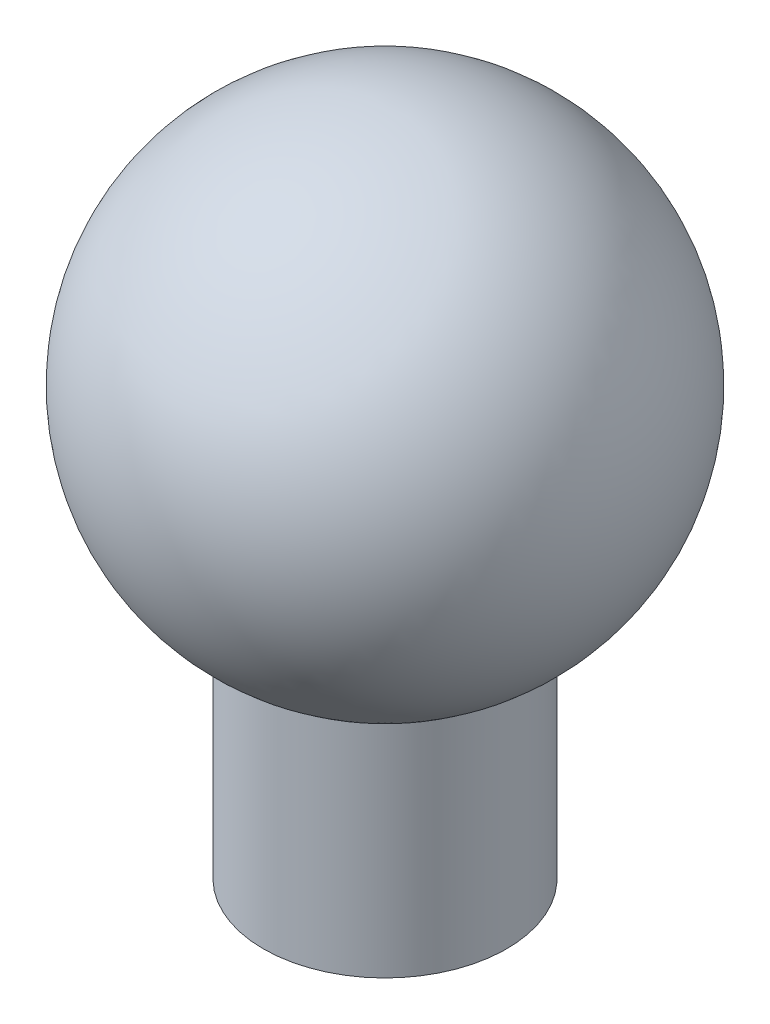
from build123d import *

# Parameters (mm, degrees)
SKETCH1_R          = 4.191
BASE_EXTRUDE_DEPTH = 7.62
SCALE1_SCALE       = 5.55


with BuildPart() as part:
    # Sketch1 → Base-Extrude (new body)
    with BuildSketch(Plane(origin=(0, 0, 0), x_dir=(1, 0, 0), z_dir=(0, 1, 0))):
        Circle(SKETCH1_R)
    extrude(amount=BASE_EXTRUDE_DEPTH)

    # Sketch2 → Boss-Revolve1 (revolve)
    with BuildSketch(Plane.XY):
        with BuildLine():
            Line((0, 22.987), (0, 6.477))
            ThreePointArc((0, 6.477), (8.255, 14.732), (0, 22.987))
        make_face()
    revolve(axis=Axis((0, 0, 0), (0, 1, 0)))


with BuildPart() as part_1:
    # Scale1: scaled about (0, 13.146971179, 0)
    add(part.part.scale(SCALE1_SCALE).moved(Location((0, -59.818718864, 0))))


solid = part_1.part
